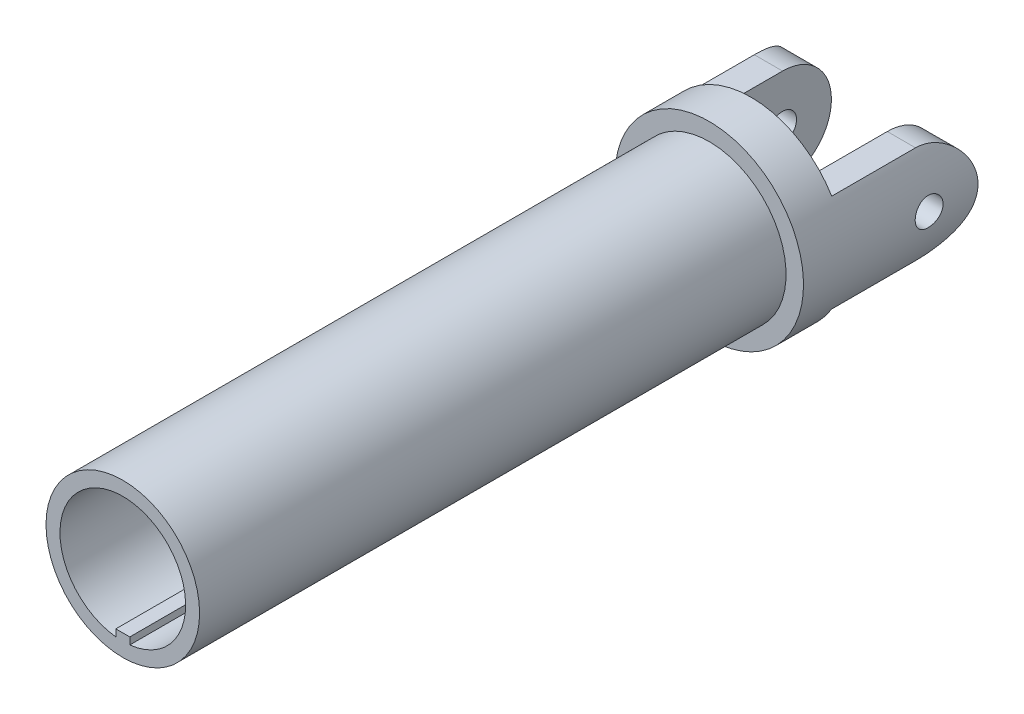
from build123d import *

# Parameters (mm, degrees)
SKETCH1_R                = 5.5
YOKE_DEPTH               = 21
SKETCH2_R                = 6.75
U_JOINT_BASE_DEPTH       = 3
U_JOINT_STANDUPS_DEPTH   = 9.5
STANDUP_ROUND_DEPTH      = 7.75
STANDUP_ROUND_DEPTH_BACK = 7.75
SKETCH5_R                = 1
BALL_HOLES_DEPTH         = 7.75
BALL_HOLES_DEPTH_BACK    = 7.75
KEYWAY_DEPTH             = 42


with BuildPart() as part:
    # Sketch1 → Yoke (new body, symmetric)
    with BuildSketch(Plane.XY):
        Circle(SKETCH1_R)
    extrude(amount=YOKE_DEPTH, both=True)

    # Sketch2 → U Joint Base (add)
    with BuildSketch(Plane(origin=(0, 0, -21), x_dir=(-1, 0, 0), z_dir=(0, 0, -1))):
        Circle(SKETCH2_R)
    extrude(amount=U_JOINT_BASE_DEPTH)

    # Sketch3 → U Joint Standups (add)
    with BuildSketch(Plane(origin=(0, 0, -24), x_dir=(-1, 0, 0), z_dir=(0, 0, -1))):
        with BuildLine():
            Line((-5.771698, 3.5), (-3.75, 3.5))
            Line((-3.75, 3.5), (-3.75, -3.5))
            Line((-3.75, -3.5), (-5.771698, -3.5))
            ThreePointArc((-5.771698, -3.5), (-6.75, 0), (-5.771698, 3.5))
        make_face()
        with BuildLine():
            Line((3.75, -3.5), (3.75, 3.5))
            Line((3.75, 3.5), (5.771698, 3.5))
            ThreePointArc((5.771698, 3.5), (6.75, 0), (5.771698, -3.5))
            Line((5.771698, -3.5), (3.75, -3.5))
        make_face()
    extrude(amount=U_JOINT_STANDUPS_DEPTH)

    # Sketch4 → Standup Round (cut, two sides)
    with BuildSketch(Plane(origin=(0, 0, 0), x_dir=(0, 0, -1), z_dir=(1, 0, 0))) as standup_round_sk:
        with BuildLine():
            ThreePointArc((30, -3.5), (32.474874, -2.474874), (33.5, 0))
            Line((33.5, 0), (33.5, -3.5))
            Line((33.5, -3.5), (30, -3.5))
        make_face()
        with BuildLine():
            ThreePointArc((33.5, 0), (32.474874, 2.474874), (30, 3.5))
            Line((30, 3.5), (33.5, 3.5))
            Line((33.5, 3.5), (33.5, 0))
        make_face()
    extrude(amount=STANDUP_ROUND_DEPTH, mode=Mode.SUBTRACT)
    extrude(standup_round_sk.sketch, amount=-STANDUP_ROUND_DEPTH_BACK, mode=Mode.SUBTRACT)

    # Sketch5 → Ball Holes (cut, two sides)
    with BuildSketch(Plane(origin=(0, 0, 0), x_dir=(0, 0, -1), z_dir=(1, 0, 0))) as ball_holes_sk:
        with Locations((30, 0)):
            Circle(SKETCH5_R)
    extrude(amount=BALL_HOLES_DEPTH, mode=Mode.SUBTRACT)
    extrude(ball_holes_sk.sketch, amount=-BALL_HOLES_DEPTH_BACK, mode=Mode.SUBTRACT)

    # Sketch6 → Keyway (cut)
    with BuildSketch(Plane.XY.offset(21)):
        with BuildLine():
            Line((0.5, -4.472136), (0.5, -3.972136))
            Line((0.5, -3.972136), (-0.5, -3.972136))
            Line((-0.5, -3.972136), (-0.5, -4.472136))
            ThreePointArc((-0.5, -4.472136), (0, 4.5), (0.5, -4.472136))
        make_face()
    extrude(amount=-KEYWAY_DEPTH, mode=Mode.SUBTRACT)


solid = part.part
